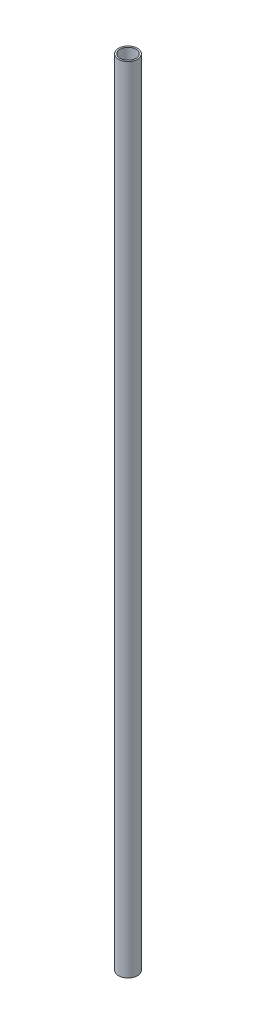
from build123d import *

# Parameters (mm, degrees)
SKETCH1_R           = 6
SKETCH1_R_2         = 5
BOSS_EXTRUDE1_DEPTH = 500


with BuildPart() as part:
    # Sketch1 → Boss-Extrude1 (new body)
    with BuildSketch(Plane(origin=(0, 0, 0), x_dir=(1, 0, 0), z_dir=(0, 1, 0))):
        Circle(SKETCH1_R)
        Circle(SKETCH1_R_2, mode=Mode.SUBTRACT)
    extrude(amount=BOSS_EXTRUDE1_DEPTH)


solid = part.part
